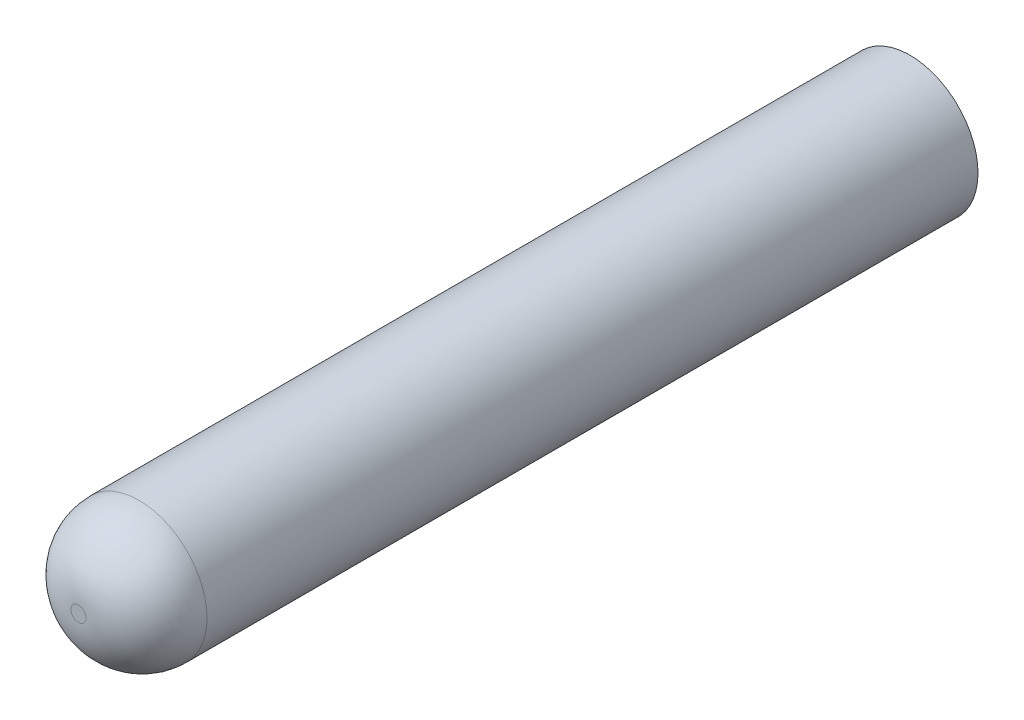
from build123d import *

# Parameters (mm, degrees)
SKETCH_1_R          = 2.25
EXTRUDE_2_DEPTH     = 27.5
SKETCH_7_W          = 2.4
SKETCH_7_H          = 2.4
CUT_EXTRUDE_3_DEPTH = 4.5
FILLET_2_R          = 2


with BuildPart() as part:
    # 草图1 → 凸台-拉伸2 (new body)
    with BuildSketch(Plane.XY):
        Circle(SKETCH_1_R)
    extrude(amount=EXTRUDE_2_DEPTH)

    # 草图7 → 切除-拉伸3 (cut)
    with BuildSketch(Plane.XY):
        Rectangle(SKETCH_7_W, SKETCH_7_H)
    extrude(amount=CUT_EXTRUDE_3_DEPTH, mode=Mode.SUBTRACT)

    # 圆角2
    fillet_2_edges = [part.edges().sort_by_distance(p)[0] for p in [
        (-2.25, 0, 27.5),
    ]]
    fillet(fillet_2_edges, radius=FILLET_2_R)


solid = part.part
